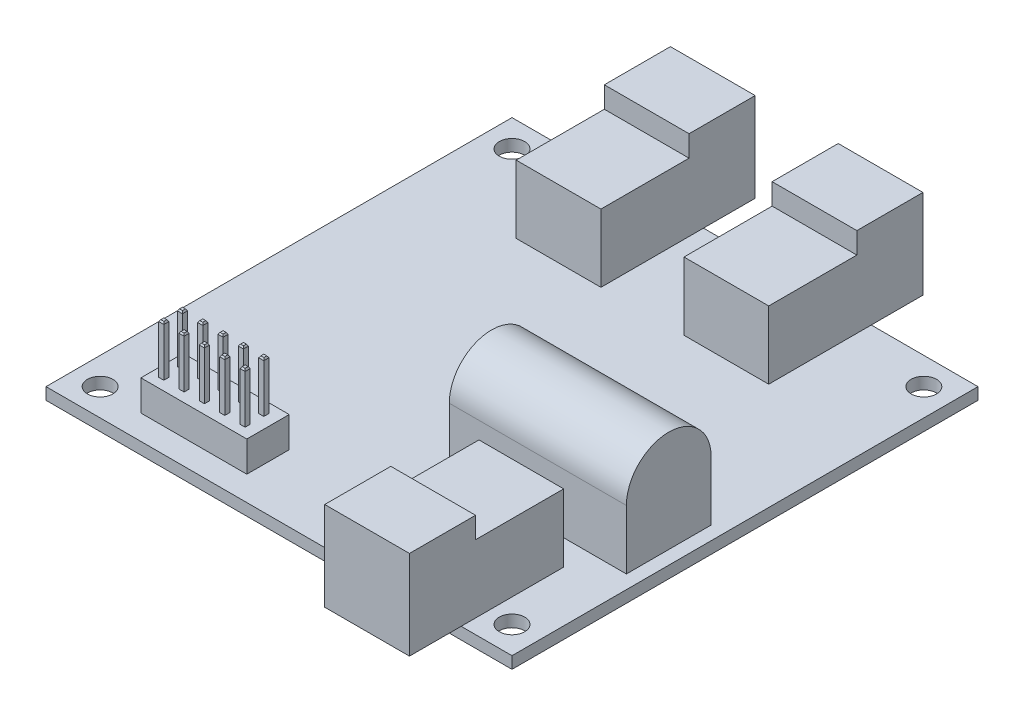
from build123d import *
from OCP.BRepFilletAPI import BRepFilletAPI_MakeChamfer

# Parameters (mm, degrees)
SKETCH1_W                   = 54.99
SKETCH1_H                   = 54.99
SKETCH1_R                   = 1.5
BOSS_EXTRUDE1_DEPTH         = 1.4
SKETCH2_W                   = 10
SKETCH2_H                   = 18.2
BOSS_EXTRUDE2_DEPTH         = 10.5
SKETCH3_W                   = 10
SKETCH3_H                   = 10.4
CUT_EXTRUDE1_DEPTH          = 2.5
SKETCH4_W                   = 12.5
SKETCH4_H                   = 5
BOSS_EXTRUDE4_DEPTH         = 3.6
SKETCH5_W                   = 0.6
SKETCH5_H                   = 0.6
BOSS_EXTRUDE5_DEPTH         = 5.9
CHAMFER1_SIZE               = 0.2
CHAMFER1_SIZE2              = 0.12497387
LPATTERN1_COUNT             = 5
LPATTERN1_PITCH             = 2.4
CHAMFER1_OF_LPATTERN1_SIZE  = 0.2
CHAMFER1_OF_LPATTERN1_SIZE2 = 0.12497387
SKETCH6_W                   = 20.9
SKETCH6_H                   = 10
BOSS_EXTRUDE6_DEPTH         = 12
CUT_EXTRUDE2_DEPTH          = 83.231625303


with BuildPart() as part:
    # Sketch1 → Boss-Extrude1 (new body)
    with BuildSketch(Plane(origin=(0, 0, 0), x_dir=(1, 0, 0), z_dir=(0, 1, 0))):
        with Locations((27.495, 27.495)):
            Rectangle(SKETCH1_W, SKETCH1_H)
        with Locations(Location((3.195, 51.795, 0), (0, 0, 270))):
            Circle(SKETCH1_R, mode=Mode.SUBTRACT)
        with Locations(Location((51.795, 51.795, 0), (0, 0, 270))):
            Circle(SKETCH1_R, mode=Mode.SUBTRACT)
        with Locations(Location((3.195, 3.195, 0), (0, 0, 270))):
            Circle(SKETCH1_R, mode=Mode.SUBTRACT)
        with Locations(Location((51.795, 3.195, 0), (0, 0, 270))):
            Circle(SKETCH1_R, mode=Mode.SUBTRACT)
    extrude(amount=BOSS_EXTRUDE1_DEPTH)

    # Sketch2 → Boss-Extrude2 (add)
    with BuildSketch(Plane(origin=(0, 1.4, 0), x_dir=(1, 0, 0), z_dir=(0, 1, 0))):
        with Locations((17.595, 51.99)):
            Rectangle(SKETCH2_W, SKETCH2_H)
        with Locations((37.395, 51.99)):
            Rectangle(SKETCH2_W, SKETCH2_H)
        with Locations((43.99, 3)):
            Rectangle(SKETCH2_W, SKETCH2_H)
    extrude(amount=BOSS_EXTRUDE2_DEPTH)

    # Sketch3 → Cut-Extrude1 (cut)
    with BuildSketch(Plane(origin=(0, 11.9, 0), x_dir=(1, 0, 0), z_dir=(0, 1, 0))):
        with Locations((37.395, 48.09)):
            Rectangle(SKETCH3_W, SKETCH3_H)
        with Locations((17.595, 48.09)):
            Rectangle(SKETCH3_W, SKETCH3_H)
        with Locations((43.99, 6.9)):
            Rectangle(SKETCH3_W, SKETCH3_H)
    extrude(amount=-CUT_EXTRUDE1_DEPTH, mode=Mode.SUBTRACT)

    # Sketch4 → Boss-Extrude4 (add)
    with BuildSketch(Plane(origin=(0, 1.4, 0), x_dir=(1, 0, 0), z_dir=(0, 1, 0))):
        with Locations((14.55, 5.4)):
            Rectangle(SKETCH4_W, SKETCH4_H)
    extrude(amount=BOSS_EXTRUDE4_DEPTH)

    # Sketch5 → Boss-Extrude5 (add)
    with BuildSketch(Plane(origin=(0, 5, 0), x_dir=(1, 0, 0), z_dir=(0, 1, 0))):
        with Locations((9.6, 6.5)):
            Rectangle(SKETCH5_W, SKETCH5_H)
        with Locations((9.6, 4.3)):
            Rectangle(SKETCH5_W, SKETCH5_H)
    boss_extrude5 = extrude(amount=BOSS_EXTRUDE5_DEPTH)

    # Chamfer1: one chamfer whose edges measure the first distance from different faces: ONE call of the kernel's chamfer builder (chamfer() names one face for all edges)
    chamfer1_edges_1 = [part.edges().sort_by_distance(p)[0] for p in [
        (9.3, 10.9, -6.5),
    ]]
    chamfer1_side_1 = [part.faces().sort_by_distance(p)[0] for p in [
        (9.3, 7.95, -6.5),
    ]]
    chamfer1_edges_2 = [part.edges().sort_by_distance(p)[0] for p in [
        (9.6, 10.9, -6.2),
    ]]
    chamfer1_side_2 = [part.faces().sort_by_distance(p)[0] for p in [
        (9.6, 7.95, -6.2),
    ]]
    chamfer1_edges_3 = [part.edges().sort_by_distance(p)[0] for p in [
        (9.9, 10.9, -6.5),
    ]]
    chamfer1_side_3 = [part.faces().sort_by_distance(p)[0] for p in [
        (9.9, 7.95, -6.5),
    ]]
    chamfer1_edges_4 = [part.edges().sort_by_distance(p)[0] for p in [
        (9.6, 10.9, -6.8),
    ]]
    chamfer1_side_4 = [part.faces().sort_by_distance(p)[0] for p in [
        (9.6, 7.95, -6.8),
    ]]
    chamfer1_edges_5 = [part.edges().sort_by_distance(p)[0] for p in [
        (9.3, 10.9, -4.3),
    ]]
    chamfer1_side_5 = [part.faces().sort_by_distance(p)[0] for p in [
        (9.3, 7.95, -4.3),
    ]]
    chamfer1_edges_6 = [part.edges().sort_by_distance(p)[0] for p in [
        (9.6, 10.9, -4),
    ]]
    chamfer1_side_6 = [part.faces().sort_by_distance(p)[0] for p in [
        (9.6, 7.95, -4),
    ]]
    chamfer1_edges_7 = [part.edges().sort_by_distance(p)[0] for p in [
        (9.9, 10.9, -4.3),
    ]]
    chamfer1_side_7 = [part.faces().sort_by_distance(p)[0] for p in [
        (9.9, 7.95, -4.3),
    ]]
    chamfer1_edges_8 = [part.edges().sort_by_distance(p)[0] for p in [
        (9.6, 10.9, -4.6),
    ]]
    chamfer1_side_8 = [part.faces().sort_by_distance(p)[0] for p in [
        (9.6, 7.95, -4.6),
    ]]
    chamfer1 = BRepFilletAPI_MakeChamfer(part.part.solid().wrapped)
    for e in chamfer1_edges_1:
        chamfer1.Add(CHAMFER1_SIZE, CHAMFER1_SIZE2, e.wrapped, chamfer1_side_1[0].wrapped)  # the first distance lies on this face
    for e in chamfer1_edges_2:
        chamfer1.Add(CHAMFER1_SIZE, CHAMFER1_SIZE2, e.wrapped, chamfer1_side_2[0].wrapped)  # the first distance lies on this face
    for e in chamfer1_edges_3:
        chamfer1.Add(CHAMFER1_SIZE, CHAMFER1_SIZE2, e.wrapped, chamfer1_side_3[0].wrapped)  # the first distance lies on this face
    for e in chamfer1_edges_4:
        chamfer1.Add(CHAMFER1_SIZE, CHAMFER1_SIZE2, e.wrapped, chamfer1_side_4[0].wrapped)  # the first distance lies on this face
    for e in chamfer1_edges_5:
        chamfer1.Add(CHAMFER1_SIZE, CHAMFER1_SIZE2, e.wrapped, chamfer1_side_5[0].wrapped)  # the first distance lies on this face
    for e in chamfer1_edges_6:
        chamfer1.Add(CHAMFER1_SIZE, CHAMFER1_SIZE2, e.wrapped, chamfer1_side_6[0].wrapped)  # the first distance lies on this face
    for e in chamfer1_edges_7:
        chamfer1.Add(CHAMFER1_SIZE, CHAMFER1_SIZE2, e.wrapped, chamfer1_side_7[0].wrapped)  # the first distance lies on this face
    for e in chamfer1_edges_8:
        chamfer1.Add(CHAMFER1_SIZE, CHAMFER1_SIZE2, e.wrapped, chamfer1_side_8[0].wrapped)  # the first distance lies on this face
    add(Compound.cast(chamfer1.Shape()), mode=Mode.REPLACE)

    # LPattern1: Boss-Extrude5 ×5
    with Locations(*[(i * LPATTERN1_PITCH, 0, 0) for i in range(1, LPATTERN1_COUNT)]):
        add(boss_extrude5)

    # Chamfer1 of LPattern1: one chamfer whose edges measure the first distance from different faces: ONE call of the kernel's chamfer builder (chamfer() names one face for all edges)
    chamfer1_of_lpattern1_edges_1 = [part.edges().sort_by_distance(p)[0] for p in [
        (11.7, 10.9, -6.5),
    ]]
    chamfer1_of_lpattern1_side_1 = [part.faces().sort_by_distance(p)[0] for p in [
        (11.7, 7.95, -6.5),
    ]]
    chamfer1_of_lpattern1_edges_2 = [part.edges().sort_by_distance(p)[0] for p in [
        (12, 10.9, -6.2),
    ]]
    chamfer1_of_lpattern1_side_2 = [part.faces().sort_by_distance(p)[0] for p in [
        (12, 7.95, -6.2),
    ]]
    chamfer1_of_lpattern1_edges_3 = [part.edges().sort_by_distance(p)[0] for p in [
        (12.3, 10.9, -6.5),
    ]]
    chamfer1_of_lpattern1_side_3 = [part.faces().sort_by_distance(p)[0] for p in [
        (12.3, 7.95, -6.5),
    ]]
    chamfer1_of_lpattern1_edges_4 = [part.edges().sort_by_distance(p)[0] for p in [
        (12, 10.9, -6.8),
    ]]
    chamfer1_of_lpattern1_side_4 = [part.faces().sort_by_distance(p)[0] for p in [
        (12, 7.95, -6.8),
    ]]
    chamfer1_of_lpattern1_edges_5 = [part.edges().sort_by_distance(p)[0] for p in [
        (11.7, 10.9, -4.3),
    ]]
    chamfer1_of_lpattern1_side_5 = [part.faces().sort_by_distance(p)[0] for p in [
        (11.7, 7.95, -4.3),
    ]]
    chamfer1_of_lpattern1_edges_6 = [part.edges().sort_by_distance(p)[0] for p in [
        (12, 10.9, -4),
    ]]
    chamfer1_of_lpattern1_side_6 = [part.faces().sort_by_distance(p)[0] for p in [
        (12, 7.95, -4),
    ]]
    chamfer1_of_lpattern1_edges_7 = [part.edges().sort_by_distance(p)[0] for p in [
        (12.3, 10.9, -4.3),
    ]]
    chamfer1_of_lpattern1_side_7 = [part.faces().sort_by_distance(p)[0] for p in [
        (12.3, 7.95, -4.3),
    ]]
    chamfer1_of_lpattern1_edges_8 = [part.edges().sort_by_distance(p)[0] for p in [
        (12, 10.9, -4.6),
    ]]
    chamfer1_of_lpattern1_side_8 = [part.faces().sort_by_distance(p)[0] for p in [
        (12, 7.95, -4.6),
    ]]
    chamfer1_of_lpattern1_edges_9 = [part.edges().sort_by_distance(p)[0] for p in [
        (14.1, 10.9, -6.5),
    ]]
    chamfer1_of_lpattern1_side_9 = [part.faces().sort_by_distance(p)[0] for p in [
        (14.1, 7.95, -6.5),
    ]]
    chamfer1_of_lpattern1_edges_10 = [part.edges().sort_by_distance(p)[0] for p in [
        (14.4, 10.9, -6.2),
    ]]
    chamfer1_of_lpattern1_side_10 = [part.faces().sort_by_distance(p)[0] for p in [
        (14.4, 7.95, -6.2),
    ]]
    chamfer1_of_lpattern1_edges_11 = [part.edges().sort_by_distance(p)[0] for p in [
        (14.7, 10.9, -6.5),
    ]]
    chamfer1_of_lpattern1_side_11 = [part.faces().sort_by_distance(p)[0] for p in [
        (14.7, 7.95, -6.5),
    ]]
    chamfer1_of_lpattern1_edges_12 = [part.edges().sort_by_distance(p)[0] for p in [
        (14.4, 10.9, -6.8),
    ]]
    chamfer1_of_lpattern1_side_12 = [part.faces().sort_by_distance(p)[0] for p in [
        (14.4, 7.95, -6.8),
    ]]
    chamfer1_of_lpattern1_edges_13 = [part.edges().sort_by_distance(p)[0] for p in [
        (14.1, 10.9, -4.3),
    ]]
    chamfer1_of_lpattern1_side_13 = [part.faces().sort_by_distance(p)[0] for p in [
        (14.1, 7.95, -4.3),
    ]]
    chamfer1_of_lpattern1_edges_14 = [part.edges().sort_by_distance(p)[0] for p in [
        (14.4, 10.9, -4),
    ]]
    chamfer1_of_lpattern1_side_14 = [part.faces().sort_by_distance(p)[0] for p in [
        (14.4, 7.95, -4),
    ]]
    chamfer1_of_lpattern1_edges_15 = [part.edges().sort_by_distance(p)[0] for p in [
        (14.7, 10.9, -4.3),
    ]]
    chamfer1_of_lpattern1_side_15 = [part.faces().sort_by_distance(p)[0] for p in [
        (14.7, 7.95, -4.3),
    ]]
    chamfer1_of_lpattern1_edges_16 = [part.edges().sort_by_distance(p)[0] for p in [
        (14.4, 10.9, -4.6),
    ]]
    chamfer1_of_lpattern1_side_16 = [part.faces().sort_by_distance(p)[0] for p in [
        (14.4, 7.95, -4.6),
    ]]
    chamfer1_of_lpattern1_edges_17 = [part.edges().sort_by_distance(p)[0] for p in [
        (16.5, 10.9, -6.5),
    ]]
    chamfer1_of_lpattern1_side_17 = [part.faces().sort_by_distance(p)[0] for p in [
        (16.5, 7.95, -6.5),
    ]]
    chamfer1_of_lpattern1_edges_18 = [part.edges().sort_by_distance(p)[0] for p in [
        (16.8, 10.9, -6.2),
    ]]
    chamfer1_of_lpattern1_side_18 = [part.faces().sort_by_distance(p)[0] for p in [
        (16.8, 7.95, -6.2),
    ]]
    chamfer1_of_lpattern1_edges_19 = [part.edges().sort_by_distance(p)[0] for p in [
        (17.1, 10.9, -6.5),
    ]]
    chamfer1_of_lpattern1_side_19 = [part.faces().sort_by_distance(p)[0] for p in [
        (17.1, 7.95, -6.5),
    ]]
    chamfer1_of_lpattern1_edges_20 = [part.edges().sort_by_distance(p)[0] for p in [
        (16.8, 10.9, -6.8),
    ]]
    chamfer1_of_lpattern1_side_20 = [part.faces().sort_by_distance(p)[0] for p in [
        (16.8, 7.95, -6.8),
    ]]
    chamfer1_of_lpattern1_edges_21 = [part.edges().sort_by_distance(p)[0] for p in [
        (16.5, 10.9, -4.3),
    ]]
    chamfer1_of_lpattern1_side_21 = [part.faces().sort_by_distance(p)[0] for p in [
        (16.5, 7.95, -4.3),
    ]]
    chamfer1_of_lpattern1_edges_22 = [part.edges().sort_by_distance(p)[0] for p in [
        (16.8, 10.9, -4),
    ]]
    chamfer1_of_lpattern1_side_22 = [part.faces().sort_by_distance(p)[0] for p in [
        (16.8, 7.95, -4),
    ]]
    chamfer1_of_lpattern1_edges_23 = [part.edges().sort_by_distance(p)[0] for p in [
        (17.1, 10.9, -4.3),
    ]]
    chamfer1_of_lpattern1_side_23 = [part.faces().sort_by_distance(p)[0] for p in [
        (17.1, 7.95, -4.3),
    ]]
    chamfer1_of_lpattern1_edges_24 = [part.edges().sort_by_distance(p)[0] for p in [
        (16.8, 10.9, -4.6),
    ]]
    chamfer1_of_lpattern1_side_24 = [part.faces().sort_by_distance(p)[0] for p in [
        (16.8, 7.95, -4.6),
    ]]
    chamfer1_of_lpattern1_edges_25 = [part.edges().sort_by_distance(p)[0] for p in [
        (18.9, 10.9, -6.5),
    ]]
    chamfer1_of_lpattern1_side_25 = [part.faces().sort_by_distance(p)[0] for p in [
        (18.9, 7.95, -6.5),
    ]]
    chamfer1_of_lpattern1_edges_26 = [part.edges().sort_by_distance(p)[0] for p in [
        (19.2, 10.9, -6.2),
    ]]
    chamfer1_of_lpattern1_side_26 = [part.faces().sort_by_distance(p)[0] for p in [
        (19.2, 7.95, -6.2),
    ]]
    chamfer1_of_lpattern1_edges_27 = [part.edges().sort_by_distance(p)[0] for p in [
        (19.5, 10.9, -6.5),
    ]]
    chamfer1_of_lpattern1_side_27 = [part.faces().sort_by_distance(p)[0] for p in [
        (19.5, 7.95, -6.5),
    ]]
    chamfer1_of_lpattern1_edges_28 = [part.edges().sort_by_distance(p)[0] for p in [
        (19.2, 10.9, -6.8),
    ]]
    chamfer1_of_lpattern1_side_28 = [part.faces().sort_by_distance(p)[0] for p in [
        (19.2, 7.95, -6.8),
    ]]
    chamfer1_of_lpattern1_edges_29 = [part.edges().sort_by_distance(p)[0] for p in [
        (18.9, 10.9, -4.3),
    ]]
    chamfer1_of_lpattern1_side_29 = [part.faces().sort_by_distance(p)[0] for p in [
        (18.9, 7.95, -4.3),
    ]]
    chamfer1_of_lpattern1_edges_30 = [part.edges().sort_by_distance(p)[0] for p in [
        (19.2, 10.9, -4),
    ]]
    chamfer1_of_lpattern1_side_30 = [part.faces().sort_by_distance(p)[0] for p in [
        (19.2, 7.95, -4),
    ]]
    chamfer1_of_lpattern1_edges_31 = [part.edges().sort_by_distance(p)[0] for p in [
        (19.5, 10.9, -4.3),
    ]]
    chamfer1_of_lpattern1_side_31 = [part.faces().sort_by_distance(p)[0] for p in [
        (19.5, 7.95, -4.3),
    ]]
    chamfer1_of_lpattern1_edges_32 = [part.edges().sort_by_distance(p)[0] for p in [
        (19.2, 10.9, -4.6),
    ]]
    chamfer1_of_lpattern1_side_32 = [part.faces().sort_by_distance(p)[0] for p in [
        (19.2, 7.95, -4.6),
    ]]
    chamfer1_of_lpattern1 = BRepFilletAPI_MakeChamfer(part.part.solid().wrapped)
    for e in chamfer1_of_lpattern1_edges_1:
        chamfer1_of_lpattern1.Add(CHAMFER1_OF_LPATTERN1_SIZE, CHAMFER1_OF_LPATTERN1_SIZE2, e.wrapped, chamfer1_of_lpattern1_side_1[0].wrapped)  # the first distance lies on this face
    for e in chamfer1_of_lpattern1_edges_2:
        chamfer1_of_lpattern1.Add(CHAMFER1_OF_LPATTERN1_SIZE, CHAMFER1_OF_LPATTERN1_SIZE2, e.wrapped, chamfer1_of_lpattern1_side_2[0].wrapped)  # the first distance lies on this face
    for e in chamfer1_of_lpattern1_edges_3:
        chamfer1_of_lpattern1.Add(CHAMFER1_OF_LPATTERN1_SIZE, CHAMFER1_OF_LPATTERN1_SIZE2, e.wrapped, chamfer1_of_lpattern1_side_3[0].wrapped)  # the first distance lies on this face
    for e in chamfer1_of_lpattern1_edges_4:
        chamfer1_of_lpattern1.Add(CHAMFER1_OF_LPATTERN1_SIZE, CHAMFER1_OF_LPATTERN1_SIZE2, e.wrapped, chamfer1_of_lpattern1_side_4[0].wrapped)  # the first distance lies on this face
    for e in chamfer1_of_lpattern1_edges_5:
        chamfer1_of_lpattern1.Add(CHAMFER1_OF_LPATTERN1_SIZE, CHAMFER1_OF_LPATTERN1_SIZE2, e.wrapped, chamfer1_of_lpattern1_side_5[0].wrapped)  # the first distance lies on this face
    for e in chamfer1_of_lpattern1_edges_6:
        chamfer1_of_lpattern1.Add(CHAMFER1_OF_LPATTERN1_SIZE, CHAMFER1_OF_LPATTERN1_SIZE2, e.wrapped, chamfer1_of_lpattern1_side_6[0].wrapped)  # the first distance lies on this face
    for e in chamfer1_of_lpattern1_edges_7:
        chamfer1_of_lpattern1.Add(CHAMFER1_OF_LPATTERN1_SIZE, CHAMFER1_OF_LPATTERN1_SIZE2, e.wrapped, chamfer1_of_lpattern1_side_7[0].wrapped)  # the first distance lies on this face
    for e in chamfer1_of_lpattern1_edges_8:
        chamfer1_of_lpattern1.Add(CHAMFER1_OF_LPATTERN1_SIZE, CHAMFER1_OF_LPATTERN1_SIZE2, e.wrapped, chamfer1_of_lpattern1_side_8[0].wrapped)  # the first distance lies on this face
    for e in chamfer1_of_lpattern1_edges_9:
        chamfer1_of_lpattern1.Add(CHAMFER1_OF_LPATTERN1_SIZE, CHAMFER1_OF_LPATTERN1_SIZE2, e.wrapped, chamfer1_of_lpattern1_side_9[0].wrapped)  # the first distance lies on this face
    for e in chamfer1_of_lpattern1_edges_10:
        chamfer1_of_lpattern1.Add(CHAMFER1_OF_LPATTERN1_SIZE, CHAMFER1_OF_LPATTERN1_SIZE2, e.wrapped, chamfer1_of_lpattern1_side_10[0].wrapped)  # the first distance lies on this face
    for e in chamfer1_of_lpattern1_edges_11:
        chamfer1_of_lpattern1.Add(CHAMFER1_OF_LPATTERN1_SIZE, CHAMFER1_OF_LPATTERN1_SIZE2, e.wrapped, chamfer1_of_lpattern1_side_11[0].wrapped)  # the first distance lies on this face
    for e in chamfer1_of_lpattern1_edges_12:
        chamfer1_of_lpattern1.Add(CHAMFER1_OF_LPATTERN1_SIZE, CHAMFER1_OF_LPATTERN1_SIZE2, e.wrapped, chamfer1_of_lpattern1_side_12[0].wrapped)  # the first distance lies on this face
    for e in chamfer1_of_lpattern1_edges_13:
        chamfer1_of_lpattern1.Add(CHAMFER1_OF_LPATTERN1_SIZE, CHAMFER1_OF_LPATTERN1_SIZE2, e.wrapped, chamfer1_of_lpattern1_side_13[0].wrapped)  # the first distance lies on this face
    for e in chamfer1_of_lpattern1_edges_14:
        chamfer1_of_lpattern1.Add(CHAMFER1_OF_LPATTERN1_SIZE, CHAMFER1_OF_LPATTERN1_SIZE2, e.wrapped, chamfer1_of_lpattern1_side_14[0].wrapped)  # the first distance lies on this face
    for e in chamfer1_of_lpattern1_edges_15:
        chamfer1_of_lpattern1.Add(CHAMFER1_OF_LPATTERN1_SIZE, CHAMFER1_OF_LPATTERN1_SIZE2, e.wrapped, chamfer1_of_lpattern1_side_15[0].wrapped)  # the first distance lies on this face
    for e in chamfer1_of_lpattern1_edges_16:
        chamfer1_of_lpattern1.Add(CHAMFER1_OF_LPATTERN1_SIZE, CHAMFER1_OF_LPATTERN1_SIZE2, e.wrapped, chamfer1_of_lpattern1_side_16[0].wrapped)  # the first distance lies on this face
    for e in chamfer1_of_lpattern1_edges_17:
        chamfer1_of_lpattern1.Add(CHAMFER1_OF_LPATTERN1_SIZE, CHAMFER1_OF_LPATTERN1_SIZE2, e.wrapped, chamfer1_of_lpattern1_side_17[0].wrapped)  # the first distance lies on this face
    for e in chamfer1_of_lpattern1_edges_18:
        chamfer1_of_lpattern1.Add(CHAMFER1_OF_LPATTERN1_SIZE, CHAMFER1_OF_LPATTERN1_SIZE2, e.wrapped, chamfer1_of_lpattern1_side_18[0].wrapped)  # the first distance lies on this face
    for e in chamfer1_of_lpattern1_edges_19:
        chamfer1_of_lpattern1.Add(CHAMFER1_OF_LPATTERN1_SIZE, CHAMFER1_OF_LPATTERN1_SIZE2, e.wrapped, chamfer1_of_lpattern1_side_19[0].wrapped)  # the first distance lies on this face
    for e in chamfer1_of_lpattern1_edges_20:
        chamfer1_of_lpattern1.Add(CHAMFER1_OF_LPATTERN1_SIZE, CHAMFER1_OF_LPATTERN1_SIZE2, e.wrapped, chamfer1_of_lpattern1_side_20[0].wrapped)  # the first distance lies on this face
    for e in chamfer1_of_lpattern1_edges_21:
        chamfer1_of_lpattern1.Add(CHAMFER1_OF_LPATTERN1_SIZE, CHAMFER1_OF_LPATTERN1_SIZE2, e.wrapped, chamfer1_of_lpattern1_side_21[0].wrapped)  # the first distance lies on this face
    for e in chamfer1_of_lpattern1_edges_22:
        chamfer1_of_lpattern1.Add(CHAMFER1_OF_LPATTERN1_SIZE, CHAMFER1_OF_LPATTERN1_SIZE2, e.wrapped, chamfer1_of_lpattern1_side_22[0].wrapped)  # the first distance lies on this face
    for e in chamfer1_of_lpattern1_edges_23:
        chamfer1_of_lpattern1.Add(CHAMFER1_OF_LPATTERN1_SIZE, CHAMFER1_OF_LPATTERN1_SIZE2, e.wrapped, chamfer1_of_lpattern1_side_23[0].wrapped)  # the first distance lies on this face
    for e in chamfer1_of_lpattern1_edges_24:
        chamfer1_of_lpattern1.Add(CHAMFER1_OF_LPATTERN1_SIZE, CHAMFER1_OF_LPATTERN1_SIZE2, e.wrapped, chamfer1_of_lpattern1_side_24[0].wrapped)  # the first distance lies on this face
    for e in chamfer1_of_lpattern1_edges_25:
        chamfer1_of_lpattern1.Add(CHAMFER1_OF_LPATTERN1_SIZE, CHAMFER1_OF_LPATTERN1_SIZE2, e.wrapped, chamfer1_of_lpattern1_side_25[0].wrapped)  # the first distance lies on this face
    for e in chamfer1_of_lpattern1_edges_26:
        chamfer1_of_lpattern1.Add(CHAMFER1_OF_LPATTERN1_SIZE, CHAMFER1_OF_LPATTERN1_SIZE2, e.wrapped, chamfer1_of_lpattern1_side_26[0].wrapped)  # the first distance lies on this face
    for e in chamfer1_of_lpattern1_edges_27:
        chamfer1_of_lpattern1.Add(CHAMFER1_OF_LPATTERN1_SIZE, CHAMFER1_OF_LPATTERN1_SIZE2, e.wrapped, chamfer1_of_lpattern1_side_27[0].wrapped)  # the first distance lies on this face
    for e in chamfer1_of_lpattern1_edges_28:
        chamfer1_of_lpattern1.Add(CHAMFER1_OF_LPATTERN1_SIZE, CHAMFER1_OF_LPATTERN1_SIZE2, e.wrapped, chamfer1_of_lpattern1_side_28[0].wrapped)  # the first distance lies on this face
    for e in chamfer1_of_lpattern1_edges_29:
        chamfer1_of_lpattern1.Add(CHAMFER1_OF_LPATTERN1_SIZE, CHAMFER1_OF_LPATTERN1_SIZE2, e.wrapped, chamfer1_of_lpattern1_side_29[0].wrapped)  # the first distance lies on this face
    for e in chamfer1_of_lpattern1_edges_30:
        chamfer1_of_lpattern1.Add(CHAMFER1_OF_LPATTERN1_SIZE, CHAMFER1_OF_LPATTERN1_SIZE2, e.wrapped, chamfer1_of_lpattern1_side_30[0].wrapped)  # the first distance lies on this face
    for e in chamfer1_of_lpattern1_edges_31:
        chamfer1_of_lpattern1.Add(CHAMFER1_OF_LPATTERN1_SIZE, CHAMFER1_OF_LPATTERN1_SIZE2, e.wrapped, chamfer1_of_lpattern1_side_31[0].wrapped)  # the first distance lies on this face
    for e in chamfer1_of_lpattern1_edges_32:
        chamfer1_of_lpattern1.Add(CHAMFER1_OF_LPATTERN1_SIZE, CHAMFER1_OF_LPATTERN1_SIZE2, e.wrapped, chamfer1_of_lpattern1_side_32[0].wrapped)  # the first distance lies on this face
    add(Compound.cast(chamfer1_of_lpattern1.Shape()), mode=Mode.REPLACE)

    # Sketch6 → Boss-Extrude6 (add)
    with BuildSketch(Plane(origin=(0, 1.4, 0), x_dir=(1, 0, 0), z_dir=(0, 1, 0))):
        with Locations((42.94, 20.1)):
            Rectangle(SKETCH6_W, SKETCH6_H)
    extrude(amount=BOSS_EXTRUDE6_DEPTH)

    # Sketch7 → Cut-Extrude2 (cut, through all)
    with BuildSketch(Plane(origin=(53.39, 0, 0), x_dir=(0, 0, -1), z_dir=(1, 0, 0))):
        with BuildLine():
            Line((15.1, 13.4), (15.1, 8.4))
            ThreePointArc((15.1, 8.4), (16.564466094, 11.935533906), (20.1, 13.4))
            Line((20.1, 13.4), (15.1, 13.4))
        make_face()
        with BuildLine():
            Line((25.1, 13.4), (20.1, 13.4))
            ThreePointArc((20.1, 13.4), (23.635533906, 11.935533906), (25.1, 8.4))
            Line((25.1, 8.4), (25.1, 13.4))
        make_face()
    extrude(amount=-CUT_EXTRUDE2_DEPTH, mode=Mode.SUBTRACT)


solid = part.part
